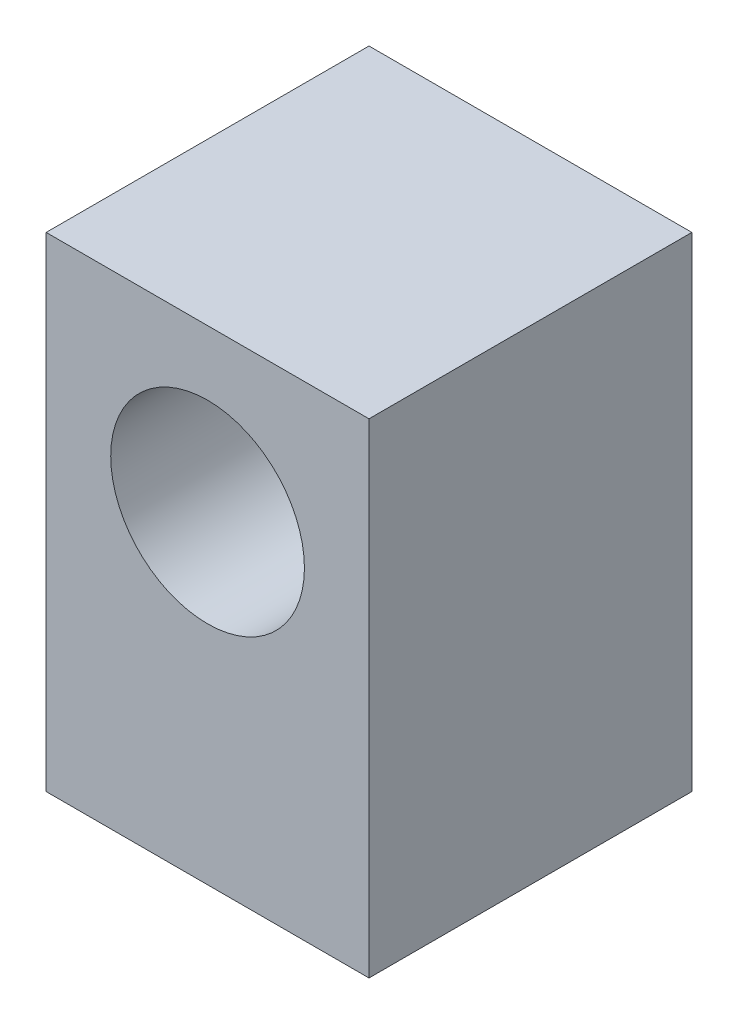
from build123d import *

# Parameters (mm, degrees)
SKETCH1_W           = 20
SKETCH1_H           = 20
BOSS_EXTRUDE2_DEPTH = 30
CUT_EXTRUDE1_REACH  = 22
SKETCH2_R           = 6


with BuildPart() as part:
    # Sketch1 → Boss-Extrude2 (new body)
    with BuildSketch(Plane(origin=(0, 0, 0), x_dir=(1, 0, 0), z_dir=(0, 1, 0))):
        Rectangle(SKETCH1_W, SKETCH1_H)
    extrude(amount=BOSS_EXTRUDE2_DEPTH)

    # Sketch2 → Cut-Extrude1 (cut, up to next)
    with BuildSketch(Plane.XY.offset(10), mode=Mode.PRIVATE) as cut_extrude1_sk1:
        with Locations((0, 20)):
            Circle(SKETCH2_R)
    cut_extrude1_tool1 = extrude(cut_extrude1_sk1.sketch, amount=-CUT_EXTRUDE1_REACH, mode=Mode.PRIVATE) & part.part
    add(cut_extrude1_tool1.solids().sort_by_distance((0, 20, 10))[0], mode=Mode.SUBTRACT)


solid = part.part
